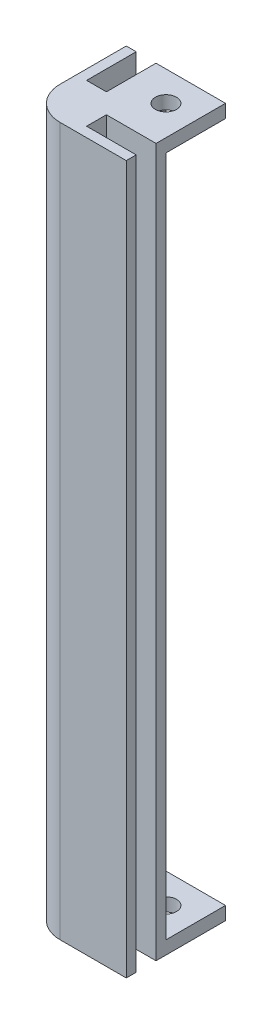
from build123d import *

# Parameters (mm, degrees)
BOSS_EXTRUDE1_DEPTH = 105
SKETCH6_R           = 1.6
BOSS_EXTRUDE2_DEPTH = 2
FILLET3_R           = 5
FILLET4_R           = 2.5
SKETCH7_R           = 1.6
BOSS_EXTRUDE3_DEPTH = 2


with BuildPart() as part:
    # Sketch4 → Boss-Extrude1 (new body)
    with BuildSketch(Plane(origin=(0, 0, 0), x_dir=(1, 0, 0), z_dir=(0, 1, 0))):
        Polygon((-7.5, -7.5), (7.5, -7.5), (7.5, -6), (0, -6), (0, -3), (7.5, -3), (7.5, -1.5), (-1.5, -1.5), (-1.5, 7.5), (-3, 7.5), (-3, 0), (-6, 0), (-6, 7.5), (-7.5, 7.5), align=None)
    extrude(amount=BOSS_EXTRUDE1_DEPTH)

    # Sketch6 → Boss-Extrude2 (add)
    with BuildSketch(Plane.XZ):
        Polygon((7.5, 7.5), (-7.5, 7.5), (-7.5, -7.5), (-6, -7.5), (-6, 0), (-3, 0), (-3, -7.5), (-1.5, -7.5), (7.5, -7.5), (7.5, 1.5), (7.5, 3), (0, 3), (0, 6), (7.5, 6), align=None)
        with Locations((3, -3)):
            Circle(SKETCH6_R, mode=Mode.SUBTRACT)
    extrude(amount=BOSS_EXTRUDE2_DEPTH)

    # Fillet3
    fillet3_edges = [part.edges().sort_by_distance(p)[0] for p in [
        (-7.5, 51.5, 7.5),
    ]]
    fillet(fillet3_edges, radius=FILLET3_R)

    # Fillet4
    fillet4_edges = [part.edges().sort_by_distance(p)[0] for p in [
        (-1.5, 52.5, 1.5),
    ]]
    fillet(fillet4_edges, radius=FILLET4_R)

    # Sketch7 → Boss-Extrude3 (add)
    with BuildSketch(Plane(origin=(0, 105, 0), x_dir=(1, 0, 0), z_dir=(0, 1, 0))):
        with BuildLine():
            Line((-1.5, 7.5), (7.5, 7.5))
            Line((7.5, 7.5), (7.5, -1.5))
            Line((7.5, -1.5), (1, -1.5))
            ThreePointArc((1, -1.5), (-0.767766953, -0.767766953), (-1.5, 1))
            Line((-1.5, 1), (-1.5, 7.5))
        make_face()
        with Locations((3, 3)):
            Circle(SKETCH7_R, mode=Mode.SUBTRACT)
    extrude(amount=-BOSS_EXTRUDE3_DEPTH)


solid = part.part
